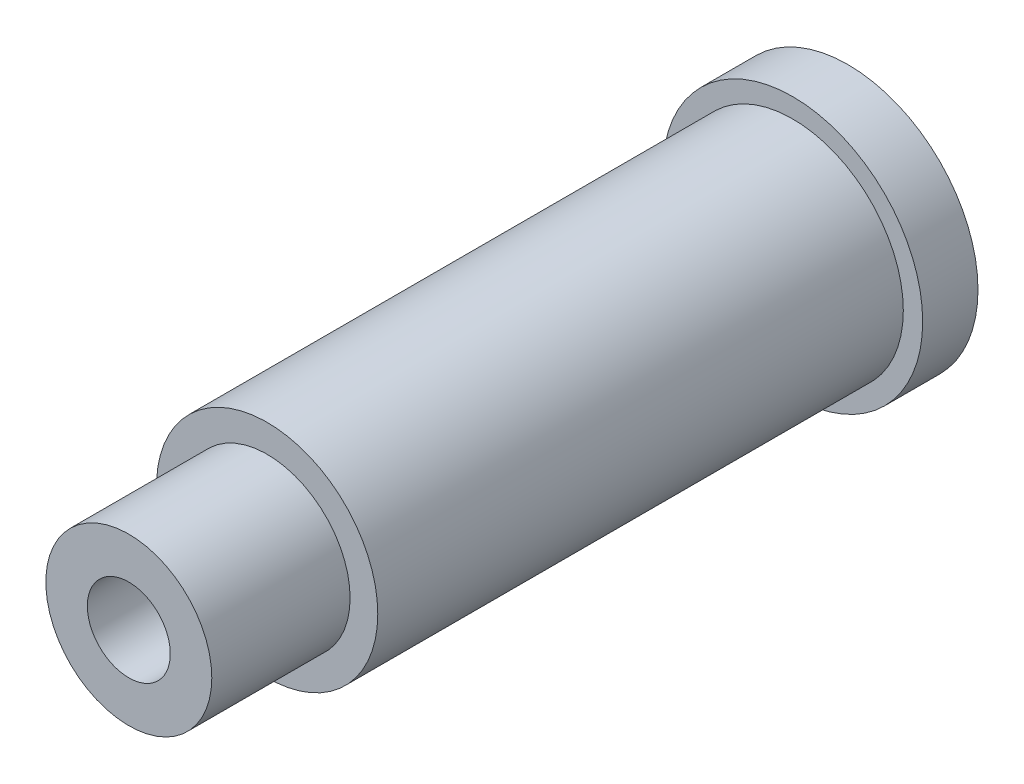
from build123d import *

# Parameters (mm, degrees)
SKETCH1_R          = 4.7
EXTRUDE1_DEPTH     = 2
SKETCH2_R          = 4
EXTRUDE2_DEPTH     = 19
SKETCH3_R          = 3
EXTRUDE3_DEPTH     = 5
SKETCH4_R          = 1.5
CUT_EXTRUDE1_DEPTH = 27


with BuildPart() as part:
    # Sketch1 → Extrude1 (new body)
    with BuildSketch(Plane.XY):
        Circle(SKETCH1_R)
    extrude(amount=EXTRUDE1_DEPTH)

    # Sketch2 → Extrude2 (add)
    with BuildSketch(Plane.XY.offset(2)):
        Circle(SKETCH2_R)
    extrude(amount=EXTRUDE2_DEPTH)

    # Sketch3 → Extrude3 (add)
    with BuildSketch(Plane.XY.offset(21)):
        Circle(SKETCH3_R)
    extrude(amount=EXTRUDE3_DEPTH)

    # Sketch4 → Cut-Extrude1 (cut, through all)
    with BuildSketch(Plane(origin=(0, 0, 0), x_dir=(-1, 0, 0), z_dir=(0, 0, -1))):
        Circle(SKETCH4_R)
    extrude(amount=-CUT_EXTRUDE1_DEPTH, mode=Mode.SUBTRACT)


solid = part.part
